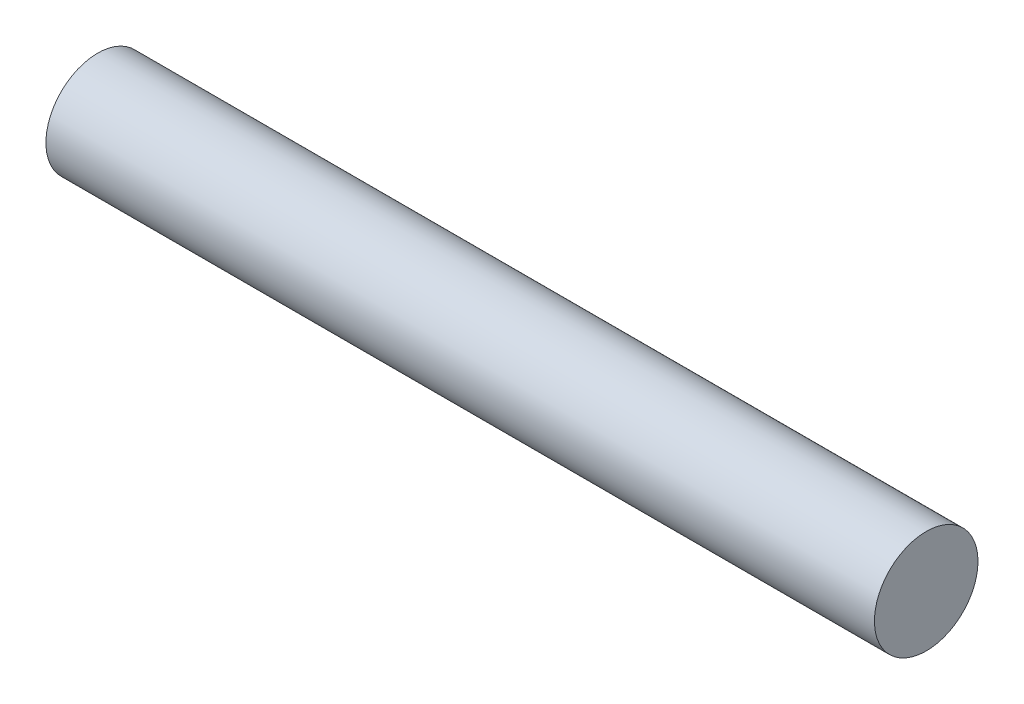
from build123d import *

# Parameters (mm, degrees)
ESQUISSE1_R        = 2.5
BOSS_EXTRU_1_DEPTH = 40


with BuildPart() as part:
    # Esquisse1 → Boss.-Extru.1 (new body)
    with BuildSketch(Plane(origin=(0, 0, 0), x_dir=(0, 0, -1), z_dir=(1, 0, 0))):
        Circle(ESQUISSE1_R)
    extrude(amount=BOSS_EXTRU_1_DEPTH)


solid = part.part
